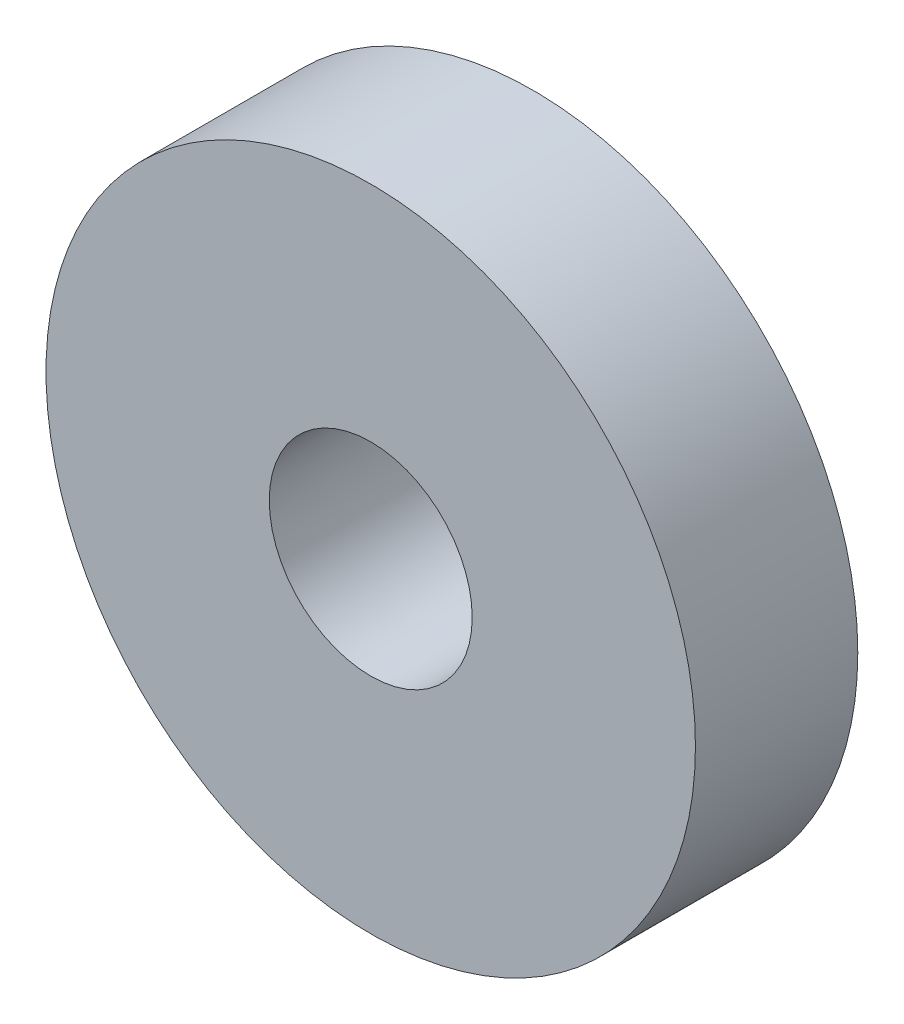
from build123d import *

# Parameters (mm, degrees)
ESQUISSE1_R          = 4
ESQUISSE1_R_2        = 1.25
BASE_EXTRUSION_DEPTH = 2


with BuildPart() as part:
    # Esquisse1 → Base-Extrusion (new body)
    with BuildSketch(Plane.XY):
        Circle(ESQUISSE1_R)
        Circle(ESQUISSE1_R_2, mode=Mode.SUBTRACT)
    extrude(amount=BASE_EXTRUSION_DEPTH)


solid = part.part
